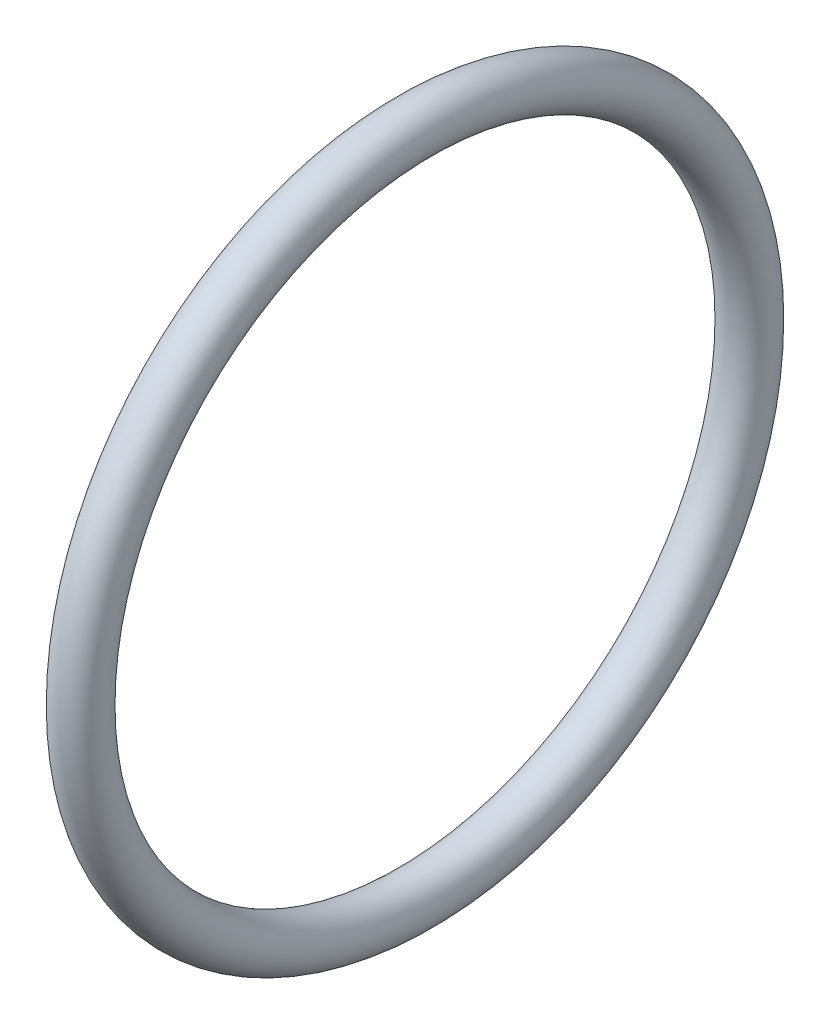
from build123d import *

# Parameters (mm, degrees)
SKETCH2_R = 1.016


with BuildPart() as part:
    # Sketch2 → Revolve3 (revolve)
    with BuildSketch(Plane.XY, mode=Mode.PRIVATE) as revolve3_sk:
        with Locations((2.54, -13.97)):
            Circle(SKETCH2_R)
    revolve(revolve3_sk.sketch.rotate(Axis((-34.684965636, 0, 0), (1, 0, 0)), 270), axis=Axis((-34.684965636, 0, 0), (1, 0, 0)))  # turned: the seam where the file's is


solid = part.part
